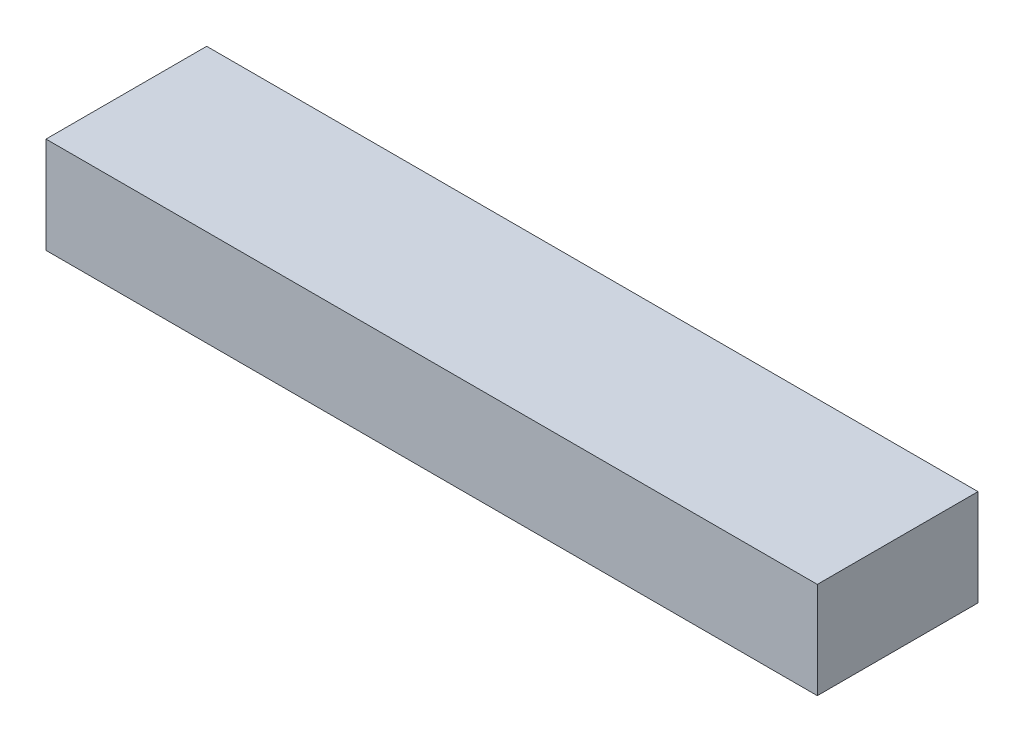
from build123d import *

# Parameters (mm, degrees)
SKETCH1_W           = 63.5
SKETCH1_H           = 38.1
BOSS_EXTRUDE1_DEPTH = 304.8


with BuildPart() as part:
    # Sketch1 → Boss-Extrude1 (new body)
    with BuildSketch(Plane(origin=(0, 0, 0), x_dir=(0, 0, -1), z_dir=(1, 0, 0))):
        with Locations((31.75, -19.05)):
            Rectangle(SKETCH1_W, SKETCH1_H)
    extrude(amount=BOSS_EXTRUDE1_DEPTH)


solid = part.part
